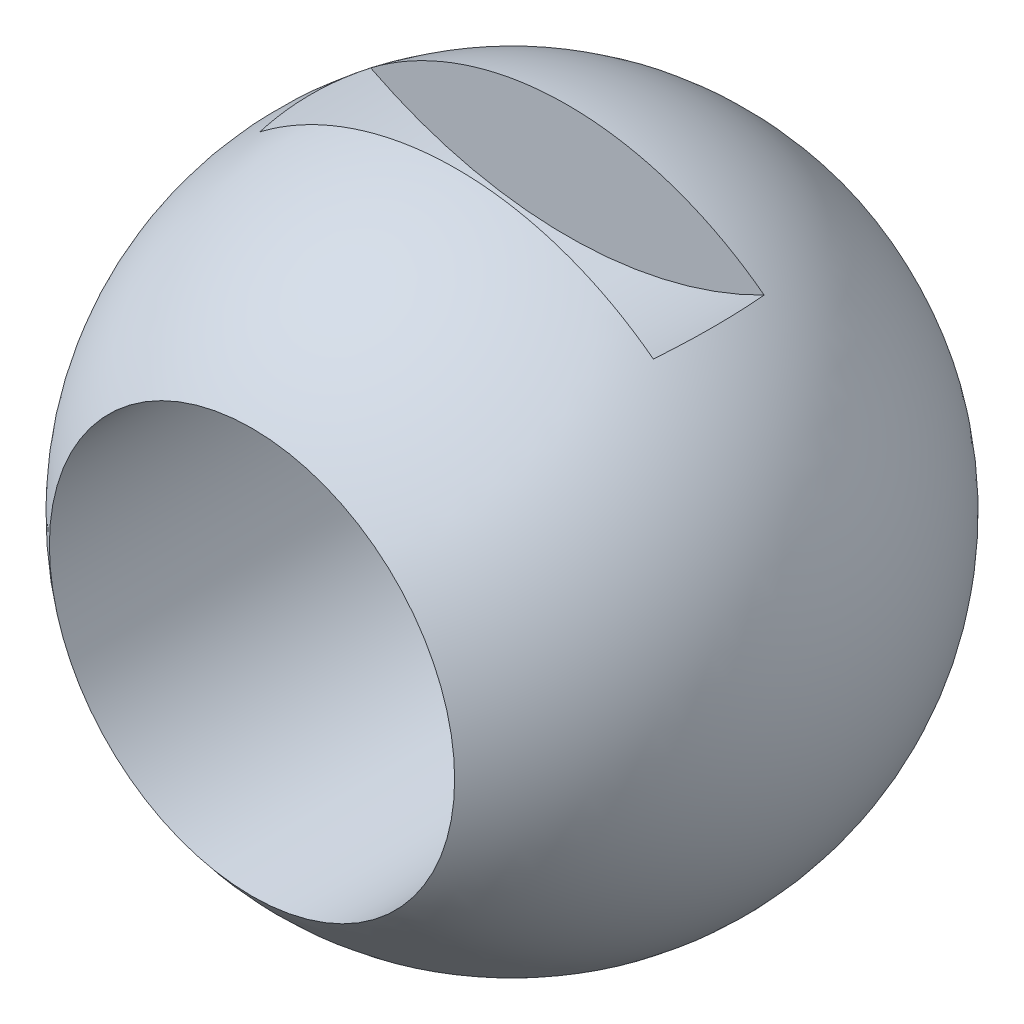
from build123d import *

# Parameters (mm, degrees)
SKETCH2_W               = 22.86
SKETCH2_H               = 3.2258
CUT_EXTRUDE1_DEPTH      = 2.6035
CUT_EXTRUDE2_DEPTH      = 2.6035
SKETCH4_R               = 9.525
CUT_EXTRUDE3_DEPTH      = 16.494
CUT_EXTRUDE3_DEPTH_BACK = 16.494


with BuildPart() as part:
    # Sketch1 → Revolve1 (revolve)
    with BuildSketch(Plane.XY):
        with BuildLine():
            Line((0, 15.494), (0, -15.494))
            ThreePointArc((0, -15.494), (-15.494, 0), (0, 15.494))
        make_face()
    revolve(axis=Axis((0, 15.494, 0), (0, -1, 0)))

    # Sketch2 → Cut-Extrude1 (cut, symmetric)
    with BuildSketch(Plane.XY):
        with Locations((0, 13.8811)):
            Rectangle(SKETCH2_W, SKETCH2_H)
    extrude(amount=CUT_EXTRUDE1_DEPTH, both=True, mode=Mode.SUBTRACT)

    # Sketch3 → Cut-Extrude2 (cut, symmetric)
    with BuildSketch(Plane.XY):
        with BuildLine():
            Line((-9.463366, 12.2682), (9.463366, 12.2682))
            ThreePointArc((9.463366, 12.2682), (0, 9.930055), (-9.463366, 12.2682))
        make_face()
    extrude(amount=CUT_EXTRUDE2_DEPTH, both=True, mode=Mode.SUBTRACT)

    # Sketch4 → Cut-Extrude3 (cut, two sides)
    with BuildSketch(Plane.XY) as cut_extrude3_sk:
        Circle(SKETCH4_R)
    extrude(amount=CUT_EXTRUDE3_DEPTH, mode=Mode.SUBTRACT)
    extrude(cut_extrude3_sk.sketch, amount=-CUT_EXTRUDE3_DEPTH_BACK, mode=Mode.SUBTRACT)


solid = part.part
